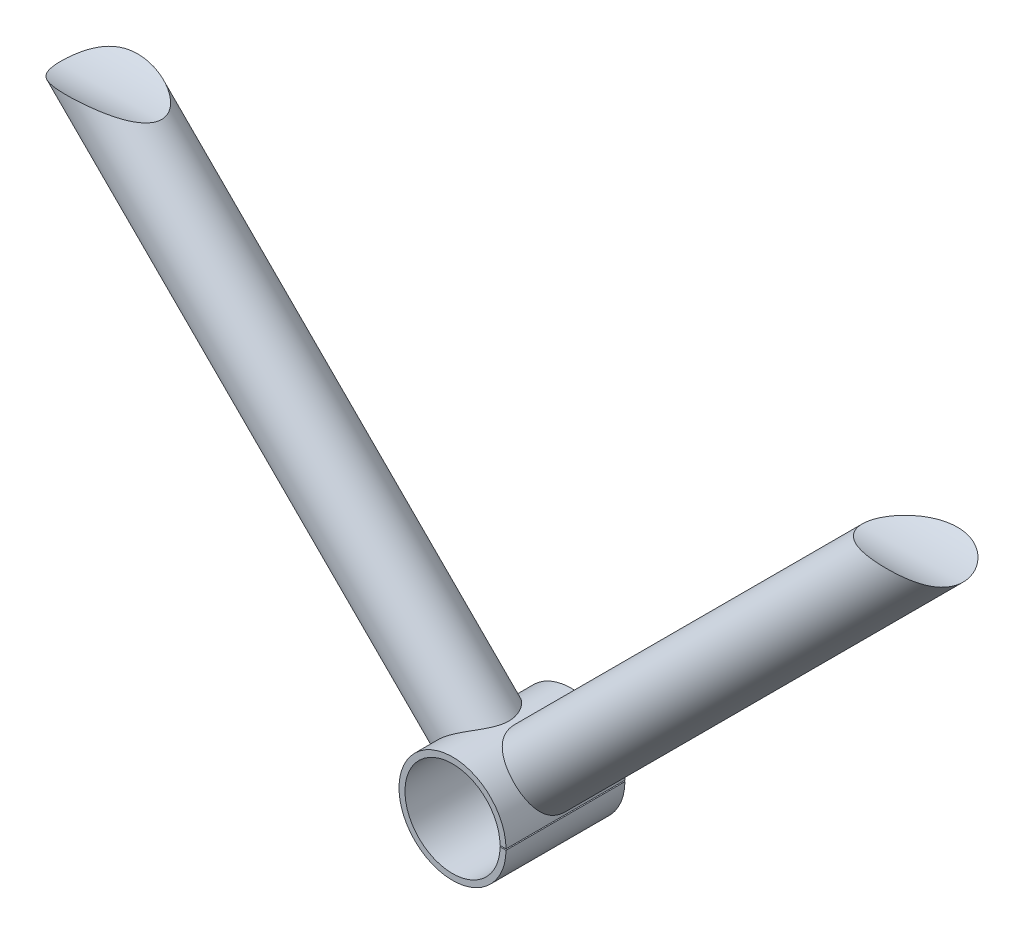
from build123d import *

# Parameters (mm, degrees)
SKETCH9_R                       = 9
SKETCH9_R_2                     = 8
BOSS_EXTRUDE1_DEPTH             = 20
SKETCH10_W                      = 4.934959926
SKETCH10_H                      = 0.2
CUT_EXTRUDE1_DEPTH              = 20
SKETCH11_R                      = 6
BOSS_EXTRUDE2_DEPTH             = 100
BOSS_EXTRUDE2_DIRECTION_2_REACH = 23.728
SKETCH12_R                      = 6
BOSS_EXTRUDE3_DEPTH             = 100
BOSS_EXTRUDE3_DIRECTION_2_REACH = 74.864
SKETCH14_R                      = 12.5
CUT_EXTRUDE3_DEPTH              = 82.317279836
CUT_EXTRUDE3_DEPTH_BACK         = 82.317279836


with BuildPart() as part:
    # Sketch9 → Boss-Extrude1 (new body)
    with BuildSketch(Plane.XY):
        Circle(SKETCH9_R)
        Circle(SKETCH9_R_2, mode=Mode.SUBTRACT)
    extrude(amount=BOSS_EXTRUDE1_DEPTH)

    # Sketch10 → Cut-Extrude1 (cut)
    with BuildSketch(Plane.XY.offset(20)):
        with Locations((8, 0)):
            Rectangle(SKETCH10_W, SKETCH10_H)
    extrude(amount=-CUT_EXTRUDE1_DEPTH, mode=Mode.SUBTRACT)

    # Sketch11 → Boss-Extrude2 (add)
    with BuildSketch(Plane(origin=(-6.363961031, 6.363961031, 0), x_dir=(0, 0, -1), z_dir=(-0.707106781, 0.707106781, 0))):
        with Locations((-10, 0)):
            Circle(SKETCH11_R)
    extrude(amount=BOSS_EXTRUDE2_DEPTH)

    # Sketch11 → Boss-Extrude2 direction 2 (add, up to next)
    with BuildSketch(Plane(origin=(-6.363961031, 6.363961031, 0), x_dir=(0, 0, -1), z_dir=(-0.707106781, 0.707106781, 0)), mode=Mode.PRIVATE) as boss_extrude2_direction_2_sk1:
        with Locations((-10, 0)):
            Circle(SKETCH11_R)
    boss_extrude2_direction_2_tool1 = extrude(boss_extrude2_direction_2_sk1.sketch, amount=-BOSS_EXTRUDE2_DIRECTION_2_REACH, mode=Mode.PRIVATE) - part.part
    add(boss_extrude2_direction_2_tool1.solids().sort_by_distance((-6.363961, 6.363961, 10))[0])
    add(boss_extrude2_direction_2_tool1.solids().sort_by_distance((-6.363961, 6.363961, 10))[1])

    # Sketch12 → Boss-Extrude3 (add)
    with BuildSketch(Plane(origin=(6.363961031, 6.363961031, 0), x_dir=(0, 0, -1), z_dir=(0.707106781, 0.707106781, 0))):
        with Locations((-10, 0)):
            Circle(SKETCH12_R)
    extrude(amount=BOSS_EXTRUDE3_DEPTH)

    # Sketch12 → Boss-Extrude3 direction 2 (add, up to next)
    with BuildSketch(Plane(origin=(6.363961031, 6.363961031, 0), x_dir=(0, 0, -1), z_dir=(0.707106781, 0.707106781, 0)), mode=Mode.PRIVATE) as boss_extrude3_direction_2_sk1:
        with Locations((-10, 0)):
            Circle(SKETCH12_R)
    boss_extrude3_direction_2_tool1 = extrude(boss_extrude3_direction_2_sk1.sketch, amount=-BOSS_EXTRUDE3_DIRECTION_2_REACH, mode=Mode.PRIVATE) - part.part
    add(boss_extrude3_direction_2_tool1.solids().sort_by_distance((6.363961, 6.363961, 10))[0])
    add(boss_extrude3_direction_2_tool1.solids().sort_by_distance((6.363961, 6.363961, 10))[1])

    # Sketch14 → Cut-Extrude3 (cut, two sides)
    with BuildSketch(Plane(origin=(0, 0, 0), x_dir=(0, 0, -1), z_dir=(1, 0, 0))) as cut_extrude3_sk:
        with Locations((-10, 79.9)):
            Circle(SKETCH14_R)
    extrude(amount=CUT_EXTRUDE3_DEPTH, mode=Mode.SUBTRACT)
    extrude(cut_extrude3_sk.sketch, amount=-CUT_EXTRUDE3_DEPTH_BACK, mode=Mode.SUBTRACT)


solid = part.part
